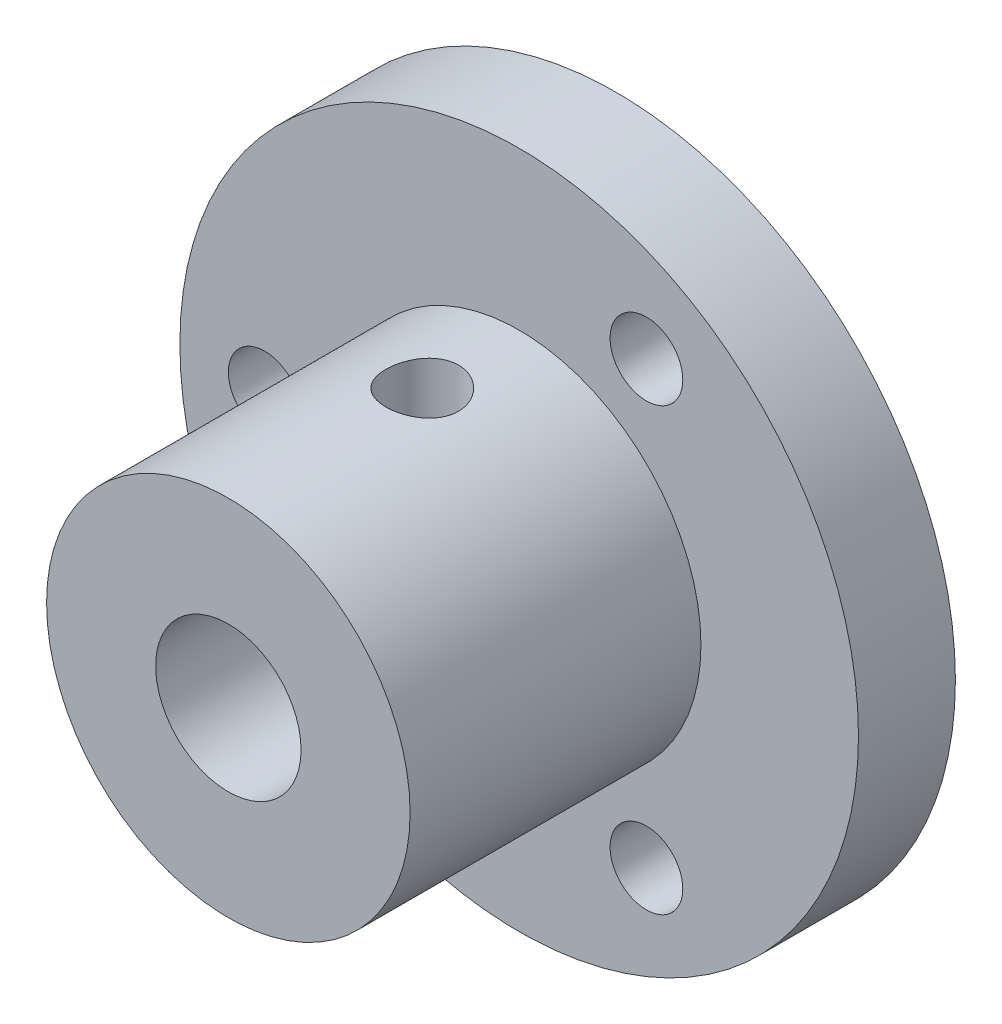
from build123d import *

# Parameters (mm, degrees)
SKETCH_1_R               = 14
SKETCH_1_R_2             = 1.5
SKETCH_1_R_3             = 3
EXTRUDE_1_DEPTH          = 4
SKETCH_3_R               = 7.5
SKETCH_3_R_2             = 3
EXTRUDE_2_DEPTH          = 12
SKETCH_4_R               = 1.5
CUT_EXTRUDE_1_DEPTH      = 15
CUT_EXTRUDE_1_DEPTH_BACK = 15


with BuildPart() as part:
    # ｽｹｯﾁ1 → ﾎﾞｽ - 押し出し1 (new body)
    with BuildSketch(Plane.XY):
        Circle(SKETCH_1_R)
        with Locations((-10.5, 0)):
            Circle(SKETCH_1_R_2, mode=Mode.SUBTRACT)
        with Locations((5.25, -9.09326674)):
            Circle(SKETCH_1_R_2, mode=Mode.SUBTRACT)
        with Locations((5.25, 9.09326674)):
            Circle(SKETCH_1_R_2, mode=Mode.SUBTRACT)
        Circle(SKETCH_1_R_3, mode=Mode.SUBTRACT)
    extrude(amount=EXTRUDE_1_DEPTH)

    # ｽｹｯﾁ3 → ﾎﾞｽ - 押し出し2 (add)
    with BuildSketch(Plane.XY.offset(4)):
        Circle(SKETCH_3_R)
        Circle(SKETCH_3_R_2, mode=Mode.SUBTRACT)
    extrude(amount=EXTRUDE_2_DEPTH)

    # ｽｹｯﾁ4 → ｶｯﾄ - 押し出し1 (cut, two sides)
    with BuildSketch(Plane(origin=(0, 0, 0), x_dir=(1, 0, 0), z_dir=(0, 1, 0))) as cut_extrude_1_sk:
        with Locations((0, -8)):
            Circle(SKETCH_4_R)
    extrude(amount=CUT_EXTRUDE_1_DEPTH, mode=Mode.SUBTRACT)
    extrude(cut_extrude_1_sk.sketch, amount=-CUT_EXTRUDE_1_DEPTH_BACK, mode=Mode.SUBTRACT)


solid = part.part
